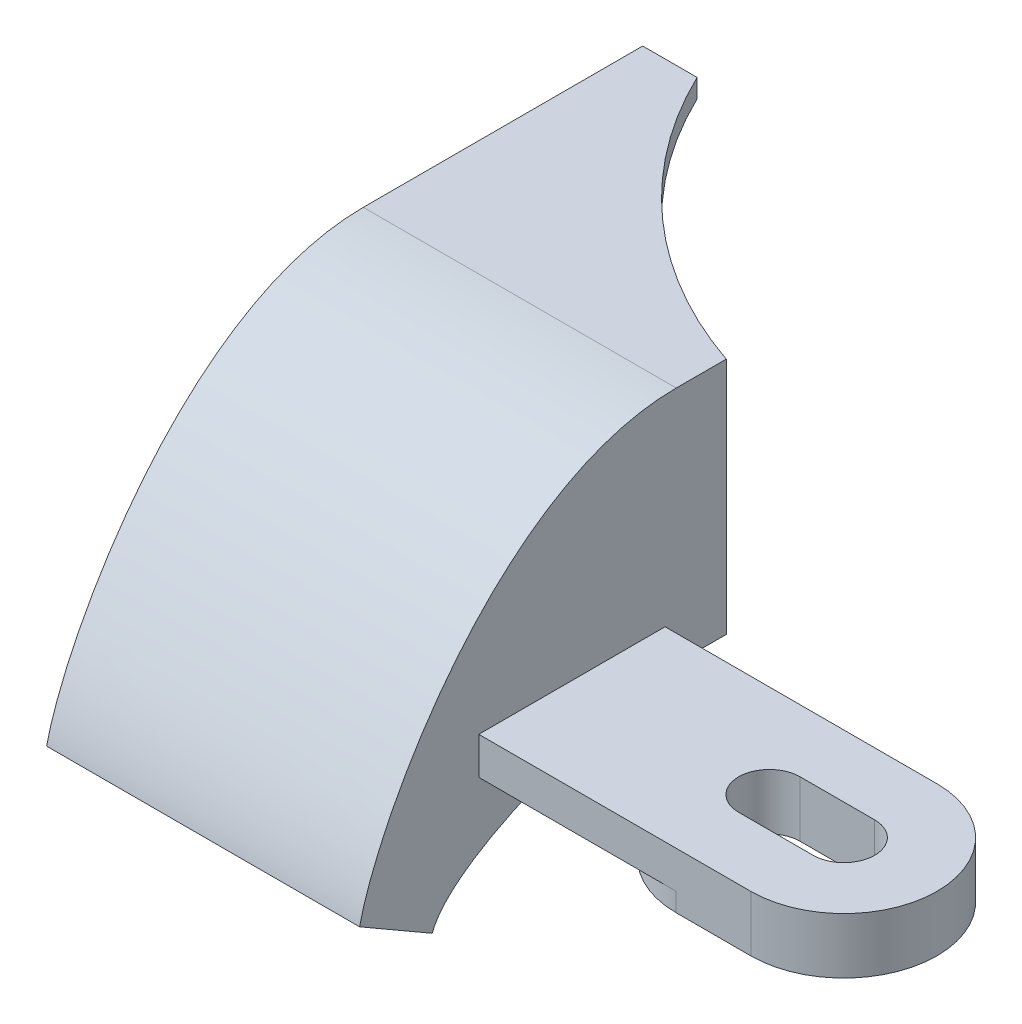
from build123d import *

# Parameters (mm, degrees)
ESBO_O1_W                = 16.8
ESBO_O1_H                = 12.8
RESSALTO_EXTRUS_O1_DEPTH = 15
RESSALTO_EXTRUS_O2_DEPTH = 16.8
CASCA1_T                 = -1
ESBO_O5_R                = 24
CORTE_EXTRUS_O1_DEPTH    = 19.8000001
RESSALTO_EXTRUS_O3_DEPTH = 2
RESSALTO_EXTRUS_O4_DEPTH = 1


with BuildPart() as part:
    # Esboço1 → Ressalto-extrusão1 (new body)
    with BuildSketch(Plane.XY):
        Rectangle(ESBO_O1_W, ESBO_O1_H)
    extrude(amount=RESSALTO_EXTRUS_O1_DEPTH)

    # Esboço2 → Ressalto-extrusão2 (add, through all)
    with BuildSketch(Plane(origin=(8.4, 0, 0), x_dir=(0, 0, -1), z_dir=(1, 0, 0))):
        with BuildLine():
            Line((-28.102885683, -12.4), (-32, -10.15))
            add(Edge.make_bspline(
                [(-15, 6.4), (-24.5700068, 6.4), (-31.06930524, -5.749171672), (-32, -10.15)],
                knots=[0, 0, 0, 0, 1, 1, 1, 1], degree=3))
            Line((-15, 6.4), (-15, -6.4))
            add(Edge.make_bspline(
                [(-15, -6.4), (-18.032161103, -6.4), (-26.944769552, -9.297903221), (-28.102885683, -12.4)],
                knots=[0, 0, 0, 0, 1, 1, 1, 1], degree=3))
        make_face()
    extrude(amount=-RESSALTO_EXTRUS_O2_DEPTH)

    # Casca1
    casca1_openings = [part.faces().sort_by_distance(p)[0] for p in [
        (0, -11.275, 30.051442841),
        (0, 0, 0),
    ]]
    offset(amount=CASCA1_T, openings=casca1_openings)

    # Esboço5 → Corte-extrusão1 (cut, through all)
    with BuildSketch(Plane(origin=(0, 6.4, 0), x_dir=(1, 0, 0), z_dir=(0, 1, 0))):
        with Locations((16.15, 10.4)):
            Circle(ESBO_O5_R)
    extrude(amount=-CORTE_EXTRUS_O1_DEPTH, mode=Mode.SUBTRACT)

    # Esboço6 → Ressalto-extrusão3 (add)
    with BuildSketch(Plane.XZ.offset(6.4)):
        with BuildLine():
            Line((23, 25.6), (8.4, 25.6))
            Line((8.4, 25.6), (8.4, 15.6))
            Line((8.4, 15.6), (23, 15.6))
            ThreePointArc((23, 15.6), (28, 20.6), (23, 25.6))
        make_face()
        with BuildLine():
            Line((19, 22.25), (23, 22.25))
            ThreePointArc((23, 22.25), (24.65, 20.6), (23, 18.95))
            Line((23, 18.95), (19, 18.95))
            ThreePointArc((19, 18.95), (17.35, 20.6), (19, 22.25))
        make_face(mode=Mode.SUBTRACT)
    extrude(amount=-RESSALTO_EXTRUS_O3_DEPTH)

    # Esboço7 → Ressalto-extrusão4 (add)
    with BuildSketch(Plane.XZ.offset(6.4)):
        with BuildLine():
            Line((19, 25.6), (23, 25.6))
            ThreePointArc((23, 25.6), (28, 20.6), (23, 15.6))
            Line((23, 15.6), (19, 15.6))
            ThreePointArc((19, 15.6), (14, 20.6), (19, 25.6))
        make_face()
        with BuildLine():
            Line((19, 18.95), (23, 18.95))
            ThreePointArc((23, 18.95), (24.65, 20.6), (23, 22.25))
            Line((23, 22.25), (19, 22.25))
            ThreePointArc((19, 22.25), (17.35, 20.6), (19, 18.95))
        make_face(mode=Mode.SUBTRACT)
    extrude(amount=RESSALTO_EXTRUS_O4_DEPTH)


solid = part.part
